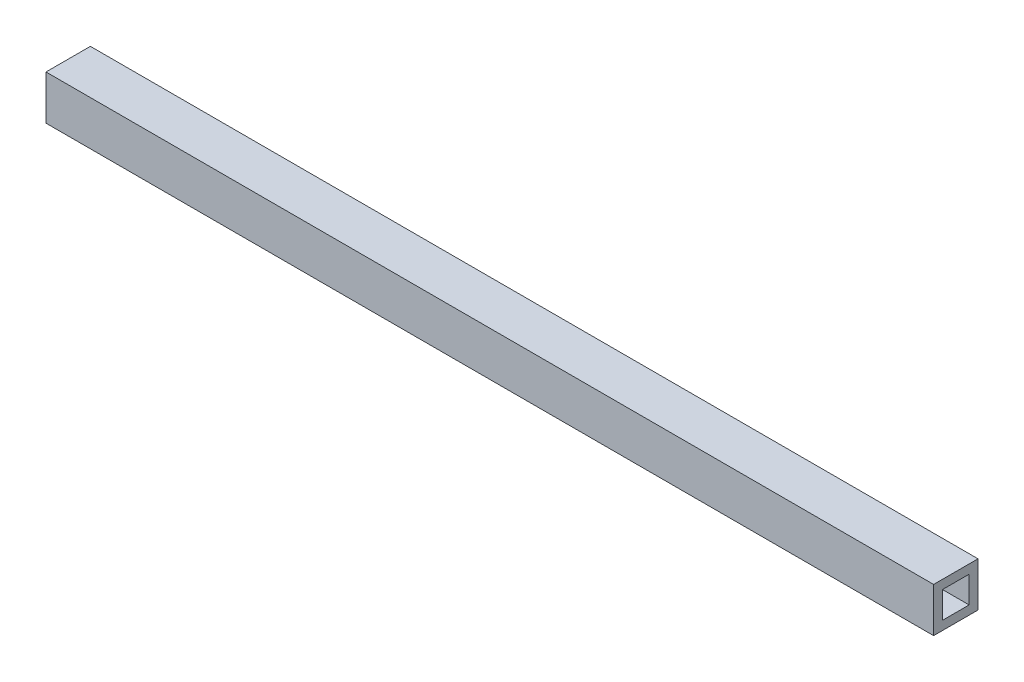
from build123d import *

# Parameters (mm, degrees)
SKETCH1_W           = 25
SKETCH1_H           = 25
BOSS_EXTRUDE1_DEPTH = 500
SKETCH2_W           = 15
SKETCH2_H           = 15
CUT_EXTRUDE1_DEPTH  = 501


with BuildPart() as part:
    # Sketch1 → Boss-Extrude1 (new body)
    with BuildSketch(Plane(origin=(0, 0, 0), x_dir=(0, 0, -1), z_dir=(1, 0, 0))):
        Rectangle(SKETCH1_W, SKETCH1_H)
    extrude(amount=BOSS_EXTRUDE1_DEPTH)

    # Sketch2 → Cut-Extrude1 (cut, through all)
    with BuildSketch(Plane(origin=(500, 0, 0), x_dir=(0, 0, -1), z_dir=(1, 0, 0))):
        Rectangle(SKETCH2_W, SKETCH2_H)
    extrude(amount=-CUT_EXTRUDE1_DEPTH, mode=Mode.SUBTRACT)


solid = part.part
